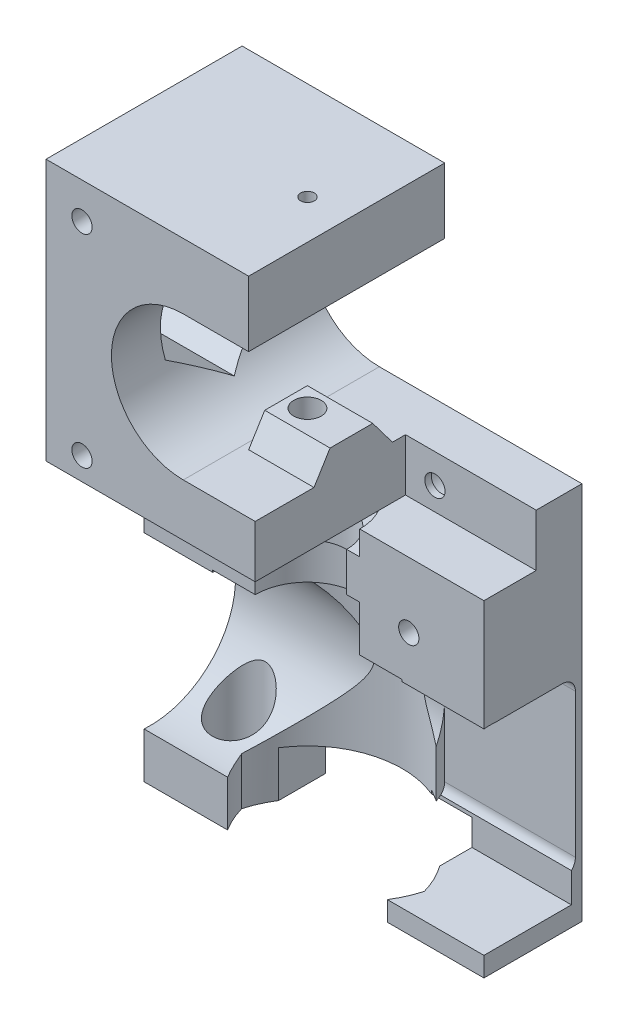
from build123d import *
from build123d.topology import SkipClean

# Parameters (mm, degrees)
CROQUIS2_R                  = 1.55
SALIENTE_EXTRUIR1_DEPTH     = 30
CROQUIS3_R                  = 2.8
CROQUIS3_R_2                = 1.55
CORTAR_EXTRUIR1_DEPTH       = 6
CROQUIS5_W                  = 10
CROQUIS5_H                  = 8
CROQUIS5_R                  = 1.55
CORTAR_EXTRUIR2_DEPTH       = 23
CROQUIS6_W                  = 42
CROQUIS6_H                  = 50
CORTAR_EXTRUIR3_DEPTH       = 15
CORTAR_EXTRUIR4_REACH       = 105.75
CROQUIS8_R                  = 1.05
CORTAR_EXTRUIR5_REACH       = 105.75
CORTAR_EXTRUIR5_END_RADIUS  = 11
CORTAR_EXTRUIR7_DEPTH       = 104.749698795
CORTAR_EXTRUIR8_DEPTH       = 98.484819374
CORTAR_EXTRUIR9_DEPTH       = 10
CORTAR_EXTRUIR10_DEPTH      = 10
CORTAR_EXTRUIR11_DEPTH      = 15
SALIENTE_EXTRUIR2_DEPTH     = 10
CROQUIS19_R                 = 1.55
CORTAR_EXTRUIR12_DEPTH      = 106.019045892
CROQUIS21_R                 = 4.05
CORTAR_EXTRUIR13_DEPTH      = 44
CORTAR_EXTRUIR14_REACH      = 110.185
CORTAR_EXTRUIR14_END_RADIUS = 4.05
CROQUIS22_R                 = 2
SALIENTE_EXTRUIR3_DEPTH     = 10
CROQUIS25_R                 = 2.1
CORTAR_EXTRUIR16_DEPTH      = 12
CROQUIS26_W                 = 24
CROQUIS26_H                 = 7
CORTAR_EXTRUIR17_DEPTH      = 106.019045892


with BuildPart() as part:
    # Croquis2 → Saliente-Extruir1 (new body)
    with BuildSketch(Plane.XY):
        with BuildLine():
            Line((0, 0), (0, 90))
            Line((0, 90), (21, 90))
            Line((21, 90), (27, 90))
            Line((27, 90), (31, 90))
            Line((31, 90), (31, 80))
            Line((31, 80), (27, 80))
            Line((27, 80), (21, 80))
            ThreePointArc((21, 80), (10, 69), (21, 58))
            Line((21, 58), (42, 58))
            Line((42, 58), (42, 0))
            Line((42, 0), (0, 0))
        make_face()
        with Locations((5.5, 84.5)):
            Circle(CROQUIS2_R, mode=Mode.SUBTRACT)
        with Locations((5.5, 53.5)):
            Circle(CROQUIS2_R, mode=Mode.SUBTRACT)
        with Locations((36.5, 53.5)):
            Circle(CROQUIS2_R, mode=Mode.SUBTRACT)
    extrude(amount=SALIENTE_EXTRUIR1_DEPTH)

    # Croquis3 → Cortar-Extruir1 (cut)
    with BuildSketch(Plane(origin=(0, 0, 0), x_dir=(-1, 0, 0), z_dir=(0, 0, -1))):
        with Locations((-36.5, 53.5)):
            Circle(CROQUIS3_R)
        with Locations((-36.5, 53.5)):
            Circle(CROQUIS3_R_2, mode=Mode.SUBTRACT)
        with Locations((-5.5, 53.5)):
            Circle(CROQUIS3_R)
        with Locations((-5.5, 53.5)):
            Circle(CROQUIS3_R_2, mode=Mode.SUBTRACT)
        with Locations((-5.5, 84.5)):
            Circle(CROQUIS3_R)
        with Locations((-5.5, 84.5)):
            Circle(CROQUIS3_R_2, mode=Mode.SUBTRACT)
    extrude(amount=-CORTAR_EXTRUIR1_DEPTH, mode=Mode.SUBTRACT)

    # Croquis5 → Cortar-Extruir2 (cut)
    with BuildSketch(Plane.XY.offset(30)):
        with Locations((37, 54)):
            Rectangle(CROQUIS5_W, CROQUIS5_H)
        with Locations(Location((36.5, 53.5, 0), (0, 0, 180))):
            Circle(CROQUIS5_R, mode=Mode.SUBTRACT)
    extrude(amount=-CORTAR_EXTRUIR2_DEPTH, mode=Mode.SUBTRACT)

    # Croquis6 → Cortar-Extruir3 (cut)
    with BuildSketch(Plane.XY.offset(30)):
        with Locations((21, 25)):
            Rectangle(CROQUIS6_W, CROQUIS6_H)
    extrude(amount=-CORTAR_EXTRUIR3_DEPTH, mode=Mode.SUBTRACT)

    # Cortar-Extruir4: up to this face of the body (flat: up to its plane)
    cortar_extruir4_end = Plane(part.part.faces().sort_by_distance((16, 50, 22.5))[0])
    # Croquis8 → Cortar-Extruir4 (cut, up to the picked face)
    with BuildSketch(Plane(origin=(0, 90, 0), x_dir=(1, 0, 0), z_dir=(0, 1, 0)), mode=Mode.PRIVATE) as cortar_extruir4_sk1:
        with Locations((25, -15)):
            Circle(CROQUIS8_R)
    cortar_extruir4_tool1 = split(extrude(cortar_extruir4_sk1.sketch, amount=-CORTAR_EXTRUIR4_REACH, mode=Mode.PRIVATE), bisect_by=cortar_extruir4_end, keep=Keep.BOTH, mode=Mode.PRIVATE)
    add(cortar_extruir4_tool1.solids().sort_by(Axis((25, 90, 15), (0, -1, 0)))[0], mode=Mode.SUBTRACT)

    # Cortar-Extruir5: up to this cylinder (the profile starts outside it)
    cortar_extruir5_end = Plane(origin=(21, 69, 15), z_dir=(0, 0, -1)) * Cylinder(CORTAR_EXTRUIR5_END_RADIUS, 234.5, mode=Mode.PRIVATE)
    # Croquis9 → Cortar-Extruir5 (cut, up to the surface)
    with BuildSketch(Plane.ZY, mode=Mode.PRIVATE) as cortar_extruir5_sk1:
        Polygon((15, 60.679491924), (22.5, 65.009618943), (22.5, 73.669872981), (15, 78), (7.5, 73.669872981), (7.5, 65.009618943), align=None)
    cortar_extruir5_tool1 = extrude(cortar_extruir5_sk1.sketch, amount=-CORTAR_EXTRUIR5_REACH, mode=Mode.PRIVATE) - cortar_extruir5_end
    add(cortar_extruir5_tool1.solids().sort_by_distance((0, 69.339746, 15))[0], mode=Mode.SUBTRACT)

    # Croquis13 → Cortar-Revolución2 (revolve, cut)
    with BuildSketch(Plane.XY.offset(15)):
        Polygon((25, 50), (17, 50), (17, 46.3), (19, 46.3), (19, 40.3), (17, 40.3), (17, 33.3), (10.5, 33.3), (10.5, 7.3), (25, 7.3), align=None)
    revolve(axis=Axis((25, 50, 15), (0, -1, 0)), mode=Mode.SUBTRACT)

    # Croquis14 → Cortar-Extruir7 (cut, through all)
    with BuildSketch(Plane.ZY):
        with BuildLine():
            Line((15, 33), (15, 7))
            ThreePointArc((15, 7), (1, 20), (15, 33))
        make_face()
    extrude(amount=-CORTAR_EXTRUIR7_DEPTH, mode=Mode.SUBTRACT)

    # Croquis15 → Cortar-Extruir8 (cut, through all)
    with BuildSketch(Plane(origin=(0, 7.3, 0), x_dir=(1, 0, 0), z_dir=(0, 1, 0))):
        with BuildLine():
            ThreePointArc((38.964653136, -11.096352631), (25, -0.5), (11.035346864, -11.096352631))
            ThreePointArc((11.035346864, -11.096352631), (25, -21.692705261), (38.964653136, -11.096352631))
        make_face()
    extrude(amount=-CORTAR_EXTRUIR8_DEPTH, mode=Mode.SUBTRACT)

    # Croquis16 → Cortar-Extruir9 (cut)
    with BuildSketch(Plane(origin=(42, 0, 0), x_dir=(0, 0, -1), z_dir=(1, 0, 0))):
        with BuildLine():
            Line((-3, 33), (-13.071428571, 33))
            ThreePointArc((-13.071428571, 33), (-4.483227698, 28.870166117), (-1, 20))
            Line((-1, 20), (-1, 31))
            ThreePointArc((-1, 31), (-1.585786438, 32.414213562), (-3, 33))
        make_face()
    extrude(amount=-CORTAR_EXTRUIR9_DEPTH, mode=Mode.SUBTRACT)

    # Croquis16_3 → Cortar-Extruir10 (cut)
    with BuildSketch(Plane(origin=(42, 0, 0), x_dir=(0, 0, -1), z_dir=(1, 0, 0))):
        with BuildLine():
            Line((-1, 9), (-1, 20))
            ThreePointArc((-1, 20), (-4.483227698, 11.129833883), (-13.071428571, 7))
            Line((-13.071428571, 7), (-3, 7))
            ThreePointArc((-3, 7), (-1.585786438, 7.585786438), (-1, 9))
        make_face()
    extrude(amount=-CORTAR_EXTRUIR10_DEPTH, mode=Mode.SUBTRACT)

    # Croquis17 → Cortar-Extruir11 (cut)
    with BuildSketch(Plane(origin=(42, 0, 0), x_dir=(0, 0, -1), z_dir=(1, 0, 0))):
        with BuildLine():
            Line((-15, 3.002611197), (-1.619150752, 3.002611197))
            Line((-1.619150752, 3.002611197), (-1.619150752, 7.553191321))
            ThreePointArc((-1.619150752, 7.553191321), (-2.256231675, 7.143441711), (-3, 7))
            Line((-3, 7), (-13.071428571, 7))
            ThreePointArc((-13.071428571, 7), (-14.035714286, 6.964285714), (-15, 7))
            Line((-15, 7), (-15, 3.002611197))
        make_face()
    extrude(amount=-CORTAR_EXTRUIR11_DEPTH, mode=Mode.SUBTRACT)

    # Croquis18 → Saliente-Extruir2 (add)
    with SkipClean():  # the faces are left unmerged after this step: merging them gives an invalid solid
        with BuildSketch(Plane(origin=(42, 0, 0), x_dir=(0, 0, -1), z_dir=(1, 0, 0))):
            with BuildLine():
                Line((-1.619150752, 3.002611197), (-15, 3.002611197))
                Line((-15, 3.002611197), (-15, 0))
                Line((-15, 0), (0, 0))
                Line((0, 0), (0, 58))
                Line((0, 58), (-7, 58))
                Line((-7, 58), (-7, 50))
                Line((-7, 50), (-15, 50))
                Line((-15, 50), (-15, 33))
                ThreePointArc((-15, 33), (-14.035714286, 33.035714286), (-13.071428571, 33))
                Line((-13.071428571, 33), (-3, 33))
                ThreePointArc((-3, 33), (-1.585786438, 32.414213562), (-1, 31))
                Line((-1, 31), (-1, 9))
                ThreePointArc((-1, 9), (-1.161291418, 8.21313867), (-1.619150752, 7.553191321))
                Line((-1.619150752, 7.553191321), (-1.619150752, 3.002611197))
            make_face()
        extrude(amount=SALIENTE_EXTRUIR2_DEPTH)

    # Croquis19 → Cortar-Extruir12 (cut, through all)
    with SkipClean():  # the faces are left unmerged after this step: merging them gives an invalid solid
        with BuildSketch(Plane.XY.offset(15)):
            with Locations((40.5, 40)):
                Circle(CROQUIS19_R)
            with Locations((12.5, 40)):
                Circle(CROQUIS19_R)
        extrude(amount=-CORTAR_EXTRUIR12_DEPTH, mode=Mode.SUBTRACT)

    # Croquis21 → Cortar-Extruir13 (cut)
    with SkipClean():  # the faces are left unmerged after this step: merging them gives an invalid solid
        with BuildSketch(Plane.XZ):
            with Locations(Location((6.5, 7, 0), (0, 0, 270))):
                Circle(CROQUIS21_R)
        extrude(amount=-CORTAR_EXTRUIR13_DEPTH, mode=Mode.SUBTRACT)

    # Cortar-Extruir14: up to this cylinder (the profile starts outside it)
    with SkipClean():  # the faces are left unmerged after this step: merging them gives an invalid solid
        cortar_extruir14_end = Plane(origin=(6.5, 42.212762, 7), z_dir=(0, -1, 0)) * Cylinder(CORTAR_EXTRUIR14_END_RADIUS, 229.47, mode=Mode.PRIVATE)
        # Croquis22 → Cortar-Extruir14 (cut, up to the surface)
        with BuildSketch(Plane.ZY, mode=Mode.PRIVATE) as cortar_extruir14_sk1:
            with Locations((7.452823222, 42.212762239)):
                Circle(CROQUIS22_R)
        cortar_extruir14_tool1 = extrude(cortar_extruir14_sk1.sketch, amount=-CORTAR_EXTRUIR14_REACH, mode=Mode.PRIVATE) - cortar_extruir14_end
        add(cortar_extruir14_tool1.solids().sort_by_distance((0, 42.212762, 7.452823))[0], mode=Mode.SUBTRACT)

    # Croquis24 → Saliente-Extruir3 (add)
    with SkipClean():  # the faces are left unmerged after this step: merging them gives an invalid solid
        with BuildSketch(Plane(origin=(32, 0, 0), x_dir=(0, 0, -1), z_dir=(1, 0, 0))):
            Polygon((-16.05, 58), (-15, 58), (-13.95, 58), (-9, 58), (-12.012359813, 62), (-18.541756759, 62), (-21, 58), align=None)
        extrude(amount=-SALIENTE_EXTRUIR3_DEPTH)

    # Croquis25 → Cortar-Extruir16 (cut)
    with SkipClean():  # the faces are left unmerged after this step: merging them gives an invalid solid
        with BuildSketch(Plane.XZ.offset(-50)):
            with Locations((25, 15)):
                Circle(CROQUIS25_R)
        extrude(amount=-CORTAR_EXTRUIR16_DEPTH, mode=Mode.SUBTRACT)

    # Croquis26 → Cortar-Extruir17 (cut, through all)
    with SkipClean():  # the faces are left unmerged after this step: merging them gives an invalid solid
        with BuildSketch(Plane.XY.offset(15)):
            with Locations((24.781319676, 3.5)):
                Rectangle(CROQUIS26_W, CROQUIS26_H)
        extrude(amount=-CORTAR_EXTRUIR17_DEPTH, mode=Mode.SUBTRACT)


solid = part.part
